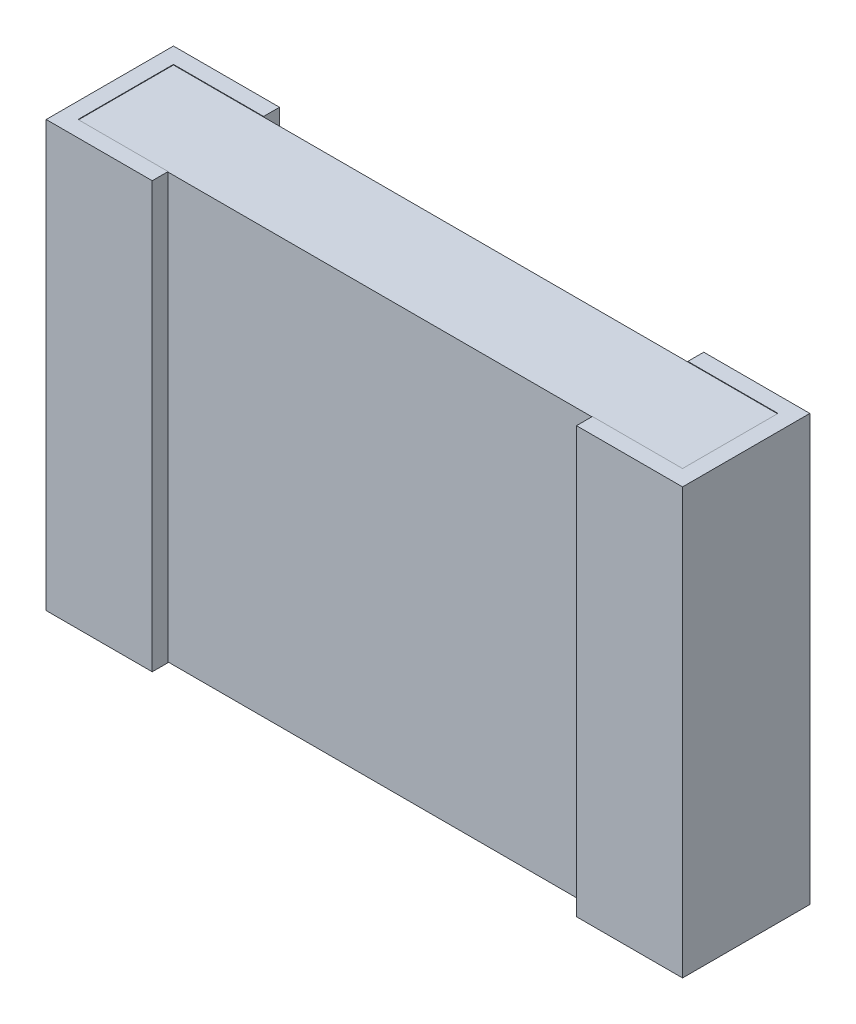
from build123d import *

# Parameters (mm, degrees)
SKETCH2_W           = 2.8956
SKETCH2_H           = 0.4572
BASE_EXTRUDE_DEPTH  = 1.016
BOSS_EXTRUDE8_DEPTH = 2.03708


with BuildPart() as part:
    # Sketch2 → Base-Extrude (new body, symmetric)
    with BuildSketch(Plane(origin=(0, 0, 0), x_dir=(1, 0, 0), z_dir=(0, 1, 0))):
        with Locations((1.524, -0.3048)):
            Rectangle(SKETCH2_W, SKETCH2_H)
    extrude(amount=BASE_EXTRUDE_DEPTH, both=True)

    # Sketch3 → Boss-Extrude8 (add)
    with BuildSketch(Plane(origin=(0, 1.01854, 0), x_dir=(-1, 0, 0), z_dir=(0, 1, 0))):
        Polygon((-0.508, 0.6096), (-0.508, 0.5334), (-0.0762, 0.5334), (-0.0762, 0.0762), (-0.508, 0.0762), (-0.508, 0), (0, 0), (0, 0.6096), align=None)
    boss_extrude8 = extrude(amount=-BOSS_EXTRUDE8_DEPTH)

    # Mirror5: Boss-Extrude8 across plane
    add(boss_extrude8.mirror(Plane(origin=(1.524, 0, 0), x_dir=(0, 0, 1), z_dir=(1, 0, 0))))


solid = part.part
